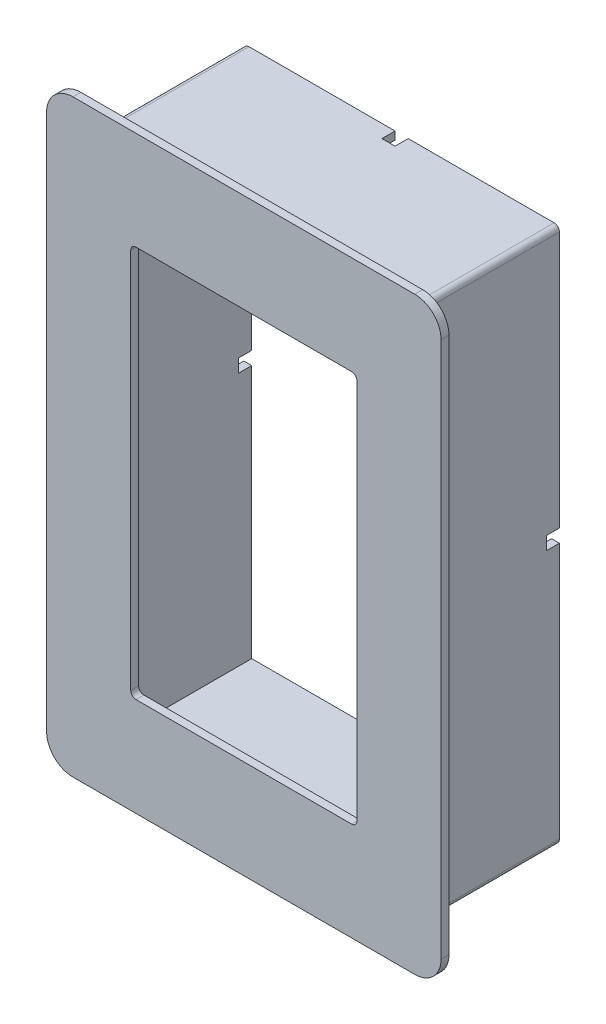
from build123d import *

# Parameters (mm, degrees)
ESBO_O1_W                = 120
ESBO_O1_H                = 204
RESSALTO_EXTRUS_O1_DEPTH = 60
ESBO_O2_W                = 114
ESBO_O2_H                = 198
CORTE_EXTRUS_O1_DEPTH    = 57
ESBO_O4_W                = 86
ESBO_O4_H                = 149
CORTE_EXTRUS_O2_DEPTH    = 45
ESBO_O7_W                = 3
ESBO_O7_H                = 204
RESSALTO_EXTRUS_O2_DEPTH = 15
ESBO_O12_W               = 3
ESBO_O12_H               = 204
RESSALTO_EXTRUS_O3_DEPTH = 15
ESBO_O13_W               = 150
ESBO_O13_H               = 3
RESSALTO_EXTRUS_O4_DEPTH = 10
ESBO_O14_W               = 150
ESBO_O14_H               = 3
RESSALTO_EXTRUS_O5_DEPTH = 10
FILETE1_R                = 10
ESBO_O15_W               = 3
ESBO_O15_H               = 5
ESBO_O15_W_2             = 5
ESBO_O15_H_2             = 3
CORTE_EXTRUS_O4_DEPTH    = 5
FILETE2_R                = 10
FILETE3_R                = 10
FILETE4_R                = 10
FILETE5_R                = 2
FILETE6_R                = 2
FILETE8_R                = 2


with BuildPart() as part:
    # Esboço1 → Ressalto-extrusão1 (new body)
    with BuildSketch(Plane.XY):
        with Locations((27.324641181, 48.820153307)):
            Rectangle(ESBO_O1_W, ESBO_O1_H)
    extrude(amount=RESSALTO_EXTRUS_O1_DEPTH)

    # Esboço2 → Corte-extrusão1 (cut)
    with BuildSketch(Plane(origin=(0, 0, 0), x_dir=(-1, 0, 0), z_dir=(0, 0, -1))):
        with Locations((-27.324641181, 48.820153307)):
            Rectangle(ESBO_O2_W, ESBO_O2_H)
    extrude(amount=-CORTE_EXTRUS_O1_DEPTH, mode=Mode.SUBTRACT)

    # Esboço4 → Corte-extrusão2 (cut)
    with BuildSketch(Plane.XY.offset(60)):
        with Locations((27.324641181, 48.820153307)):
            Rectangle(ESBO_O4_W, ESBO_O4_H)
    extrude(amount=-CORTE_EXTRUS_O2_DEPTH, mode=Mode.SUBTRACT)

    # Esboço7 → Ressalto-extrusão2 (add)
    with BuildSketch(Plane(origin=(87.324641181, 0, 0), x_dir=(0, 0, -1), z_dir=(1, 0, 0))):
        with Locations((-58.5, 48.820153307)):
            Rectangle(ESBO_O7_W, ESBO_O7_H)
    extrude(amount=RESSALTO_EXTRUS_O2_DEPTH)

    # Esboço12 → Ressalto-extrusão3 (add)
    with BuildSketch(Plane.ZY.offset(32.675358819)):
        with Locations((58.5, 48.820153307)):
            Rectangle(ESBO_O12_W, ESBO_O12_H)
    extrude(amount=RESSALTO_EXTRUS_O3_DEPTH)

    # Esboço13 → Ressalto-extrusão4 (add)
    with BuildSketch(Plane(origin=(0, 150.820153307, 0), x_dir=(1, 0, 0), z_dir=(0, 1, 0))):
        with Locations((27.324641181, -58.5)):
            Rectangle(ESBO_O13_W, ESBO_O13_H)
    extrude(amount=RESSALTO_EXTRUS_O4_DEPTH)

    # Esboço14 → Ressalto-extrusão5 (add)
    with BuildSketch(Plane.XZ.offset(53.179846693)):
        with Locations((27.324641181, 58.5)):
            Rectangle(ESBO_O14_W, ESBO_O14_H)
    extrude(amount=RESSALTO_EXTRUS_O5_DEPTH)

    # Filete1
    filete1_edges = [part.edges().sort_by_distance(p)[0] for p in [
        (102.324641181, 160.820153307, 58.5),
    ]]
    fillet(filete1_edges, radius=FILETE1_R)

    # Esboço15 → Corte-extrusão4 (cut)
    with BuildSketch(Plane(origin=(0, 0, 0), x_dir=(-1, 0, 0), z_dir=(0, 0, -1))):
        with Locations((31.175358819, 48.820153307)):
            Rectangle(ESBO_O15_W, ESBO_O15_H)
        with Locations((-27.324641181, 149.320153307)):
            Rectangle(ESBO_O15_W_2, ESBO_O15_H_2)
        with Locations((-27.324641181, -51.679846693)):
            Rectangle(ESBO_O15_W_2, ESBO_O15_H_2)
        with Locations((-85.824641181, 48.820153307)):
            Rectangle(ESBO_O15_W, ESBO_O15_H)
    extrude(amount=-CORTE_EXTRUS_O4_DEPTH, mode=Mode.SUBTRACT)

    # Filete2
    filete2_edges = [part.edges().sort_by_distance(p)[0] for p in [
        (-47.675358819, 160.820153307, 58.5),
    ]]
    fillet(filete2_edges, radius=FILETE2_R)

    # Filete3
    filete3_edges = [part.edges().sort_by_distance(p)[0] for p in [
        (102.324641181, -63.179846693, 58.5),
    ]]
    fillet(filete3_edges, radius=FILETE3_R)

    # Filete4
    filete4_edges = [part.edges().sort_by_distance(p)[0] for p in [
        (-47.675358819, -63.179846693, 58.5),
    ]]
    fillet(filete4_edges, radius=FILETE4_R)

    # Filete5
    filete5_edges = [part.edges().sort_by_distance(p)[0] for p in [
        (-32.675358819, -53.179846693, 28.5),
    ]]
    fillet(filete5_edges, radius=FILETE5_R)

    # Filete6
    filete6_edges = [part.edges().sort_by_distance(p)[0] for p in [
        (-32.675358819, 150.820153307, 28.5),
        (87.324641181, 150.820153307, 28.5),
        (87.324641181, -53.179846693, 28.5),
    ]]
    fillet(filete6_edges, radius=FILETE6_R)

    # Filete8
    filete8_edges = [part.edges().sort_by_distance(p)[0] for p in [
        (-15.675358819, 123.320153307, 58.5),
        (70.324641181, 123.320153307, 58.5),
        (70.324641181, -25.679846693, 58.5),
        (-15.675358819, -25.679846693, 58.5),
    ]]
    fillet(filete8_edges, radius=FILETE8_R)


solid = part.part
